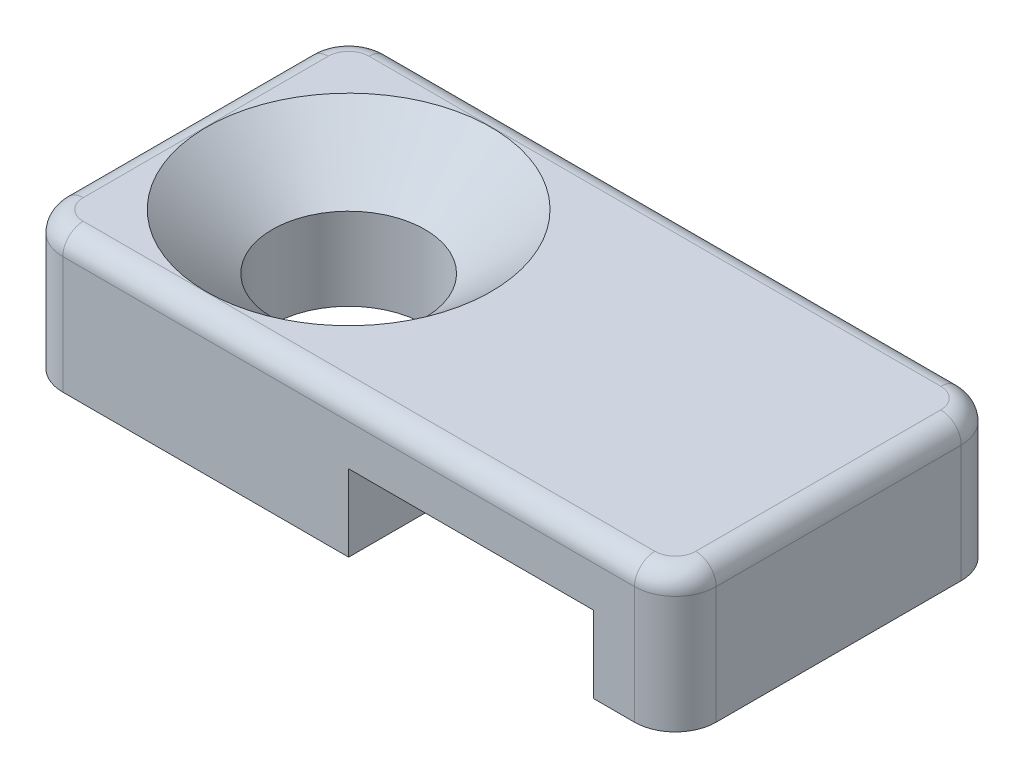
from build123d import *

# Parameters (mm, degrees)
BOSS_EXTRUDE1_DEPTH                               = 4.064
CSK_FOR_6_FLAT_HEAD_MACHINE_SCREW_100_D           = 3.7973
CSK_FOR_6_FLAT_HEAD_MACHINE_SCREW_100_CSINK_D     = 7.0866
CSK_FOR_6_FLAT_HEAD_MACHINE_SCREW_100_CSINK_ANGLE = 100
FILLET1_R                                         = 1.016
FILLET2_R                                         = 0.508


with BuildPart() as part:
    # Sketch1 → Boss-Extrude1 (new body, symmetric)
    with BuildSketch(Plane.XY):
        Polygon((0, 0), (0, 1.905), (6.096, 1.905), (6.096, 0), (8.128, 0), (8.128, 3.429), (-8.128, 3.429), (-8.128, 0), align=None)
    extrude(amount=BOSS_EXTRUDE1_DEPTH, both=True)

    # CSK for #6 Flat Head Machine Screw (100)1 (through all)
    with Locations(Plane(origin=(0, 3.429, 0), x_dir=(1, 0, 0), z_dir=(0, 1, 0))):
        with Locations((-4.064, 0)):
            CounterSinkHole(CSK_FOR_6_FLAT_HEAD_MACHINE_SCREW_100_D / 2, CSK_FOR_6_FLAT_HEAD_MACHINE_SCREW_100_CSINK_D / 2, counter_sink_angle=CSK_FOR_6_FLAT_HEAD_MACHINE_SCREW_100_CSINK_ANGLE)

    # Fillet1
    fillet1_edges = [part.edges().sort_by_distance(p)[0] for p in [
        (-8.128, 1.7145, -4.064),
        (8.128, 1.7145, 4.064),
        (8.128, 1.7145, -4.064),
        (-8.128, 1.7145, 4.064),
    ]]
    fillet(fillet1_edges, radius=FILLET1_R)

    # Fillet2
    fillet2_edges = [part.edges().sort_by_distance(p)[0] for p in [
        (8.128, 3.429, 0),
        (0, 3.429, -4.064),
        (-8.128, 3.429, 0),
        (0, 3.429, 4.064),
        (-7.83042049, 3.429, 3.76642049),
        (-7.83042049, 3.429, -3.76642049),
        (7.83042049, 3.429, 3.76642049),
        (7.83042049, 3.429, -3.76642049),
    ]]
    fillet(fillet2_edges, radius=FILLET2_R)


solid = part.part
